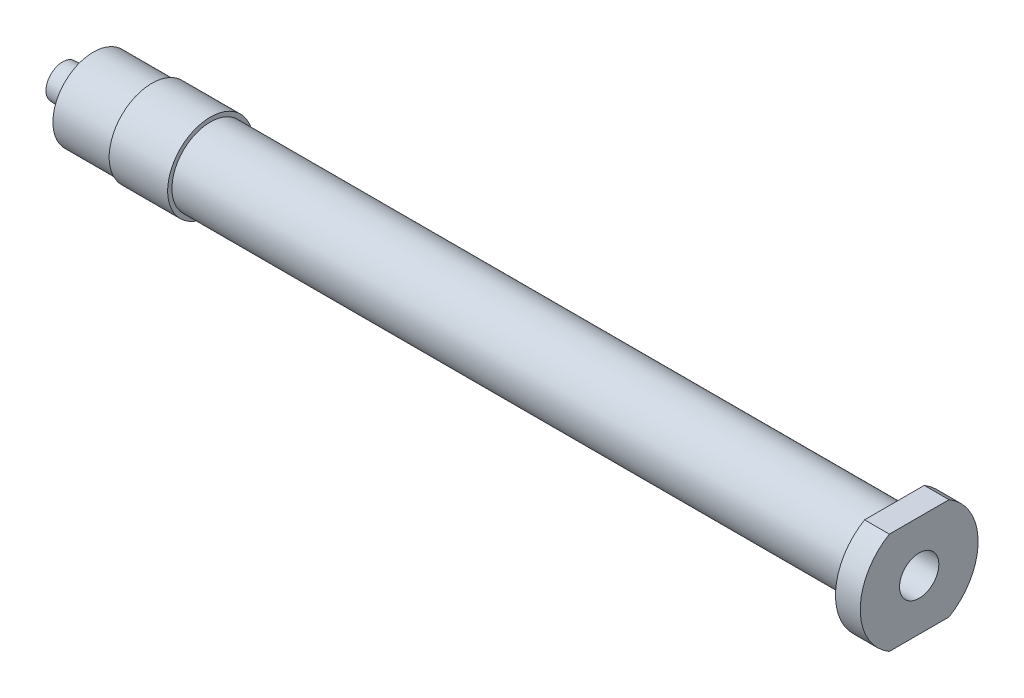
from build123d import *

# Parameters (mm, degrees)
SKETCH2_W          = 19
SKETCH2_H          = 15.9
SKETCH2_W_2        = 15
SKETCH2_H_2        = 11.9
CUT_EXTRUDE1_DEPTH = 2.9


with BuildPart() as part:
    # Sketch1 → Revolve1 (revolve)
    with BuildSketch(Plane(origin=(0, 0, 0), x_dir=(1, 0, 0), z_dir=(0, 1, 0))):
        Polygon((-50.15, 0.75), (-50.15, 1.95), (-43.05, 2.322095233), (-43.05, 4.1), (-46.55, 4.1), (-46.55, 4.74), (-39.7, 4.74), (-39.7, 5), (-32.85, 5), (-32.85, 4.5), (47.25, 4.5), (47.25, 6.9), (50.15, 6.9), (50.15, 2.3), (-32.85, 2.3), (-32.85, 0.75), align=None)
    revolve(axis=Axis((50.15, 0, 0), (-1, 0, 0)))

    # Sketch2 → Cut-Extrude1 (cut)
    with BuildSketch(Plane(origin=(50.15, 0, 0), x_dir=(0, 0, -1), z_dir=(1, 0, 0))):
        Rectangle(SKETCH2_W, SKETCH2_H)
        Rectangle(SKETCH2_W_2, SKETCH2_H_2, mode=Mode.SUBTRACT)
    extrude(amount=-CUT_EXTRUDE1_DEPTH, mode=Mode.SUBTRACT)


solid = part.part
